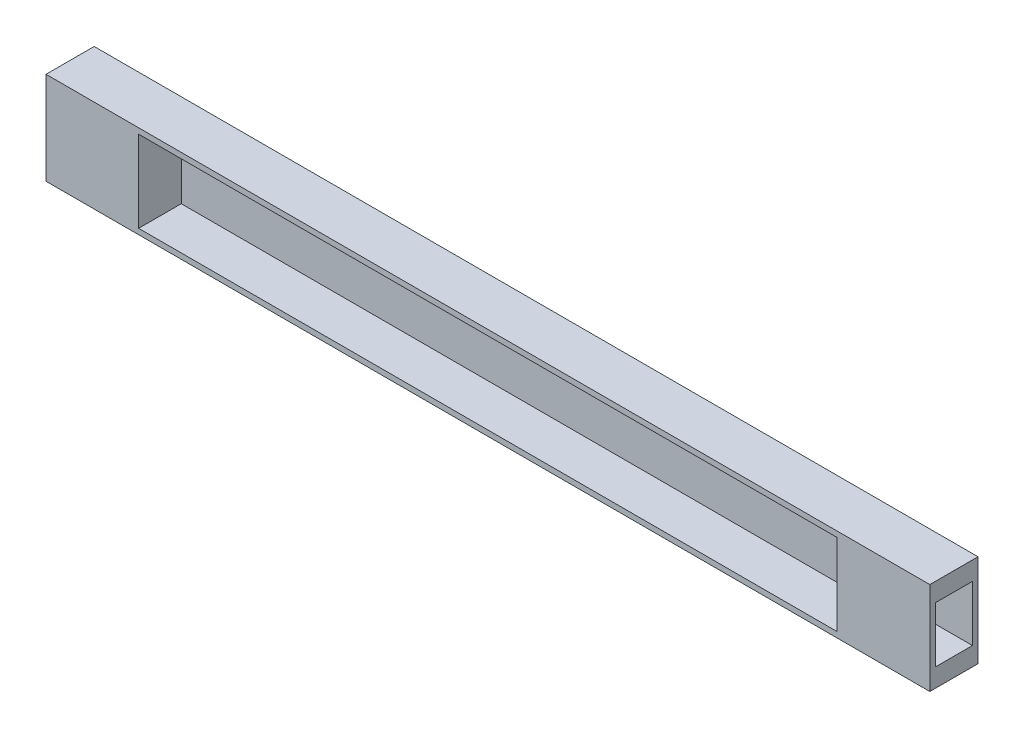
from build123d import *

# Parameters (mm, degrees)
SKETCH1_W           = 477.000009268
SKETCH1_H           = 50.00000447
BOSS_EXTRUDE1_DEPTH = 25.999993086
SKETCH2_W           = 23.000001907
SKETCH2_H           = 43.999992311
CUT_EXTRUDE1_DEPTH  = 426.999997348
SKETCH3_W           = 19.999980927
SKETCH3_H           = 30.000001192
CUT_EXTRUDE2_DEPTH  = 30.000001192
MOVE_FACE1_BY       = 238.5
MOVE_FACE2_BY       = 30
SKETCH6_W           = 20
SKETCH6_H           = 30
CUT_EXTRUDE3_DEPTH  = 30
SKETCH7_W           = 20
SKETCH7_H           = 20
BOSS_EXTRUDE3_DEPTH = 10


with BuildPart() as part:
    # Sketch1 → Boss-Extrude1 (new body)
    with BuildSketch(Plane.XY.offset(513.999998569)):
        with Locations((177.500003949, 144.999999553)):
            Rectangle(SKETCH1_W, SKETCH1_H)
    extrude(amount=-BOSS_EXTRUDE1_DEPTH)

    # Sketch2 → Cut-Extrude1 (cut)
    with BuildSketch(Plane.ZY.offset(61.000000685)):
        with Locations((502.499997616, 144.999999553)):
            Rectangle(SKETCH2_W, SKETCH2_H)
    extrude(amount=-CUT_EXTRUDE1_DEPTH, mode=Mode.SUBTRACT)

    # Sketch3 → Cut-Extrude2 (cut)
    with BuildSketch(Plane(origin=(416.000008583, 0, 0), x_dir=(0, 0, -1), z_dir=(1, 0, 0))):
        with Locations((-500.999987126, 144.999995828)):
            Rectangle(SKETCH3_W, SKETCH3_H)
    extrude(amount=-CUT_EXTRUDE2_DEPTH, mode=Mode.SUBTRACT)

    # Move Face1: a face moved inward by 238.5
    extrude(part.faces().sort_by_distance((-61.000000685, 144.999999553, 490.600004792))[0], amount=MOVE_FACE1_BY, dir=(1, 0, 0), mode=Mode.SUBTRACT)

    # Move Face2: a face moved outward by 30.0
    extrude(part.faces().sort_by_distance((386.000007391, 144.999995828, 500.999987125))[0], amount=MOVE_FACE2_BY, dir=(1, 0, 0))

    # Sketch6 → Cut-Extrude3 (cut)
    with BuildSketch(Plane(origin=(416.000008583, 0, 0), x_dir=(0, 0, -1), z_dir=(1, 0, 0))):
        with Locations((-501.000002027, 144.999999553)):
            Rectangle(SKETCH6_W, SKETCH6_H)
    extrude(amount=-CUT_EXTRUDE3_DEPTH, mode=Mode.SUBTRACT)

    # Mirror3: part across plane


with BuildPart() as part_1:
    add(part.part)
    add(part.part.mirror(Plane(origin=(177.499999315, 170.000001788, 488.000005484), x_dir=(0, 0, 1), z_dir=(-1, 0, 0))))

    # Sketch7 → Boss-Extrude3 (add)
    with BuildSketch(Plane(origin=(0, 0, 488.000005484), x_dir=(-1, 0, 0), z_dir=(0, 0, -1))):
        with Locations((-177.499999315, 144.999999553)):
            Rectangle(SKETCH7_W, SKETCH7_H)
    extrude(amount=BOSS_EXTRUDE3_DEPTH)


solid = part_1.part
